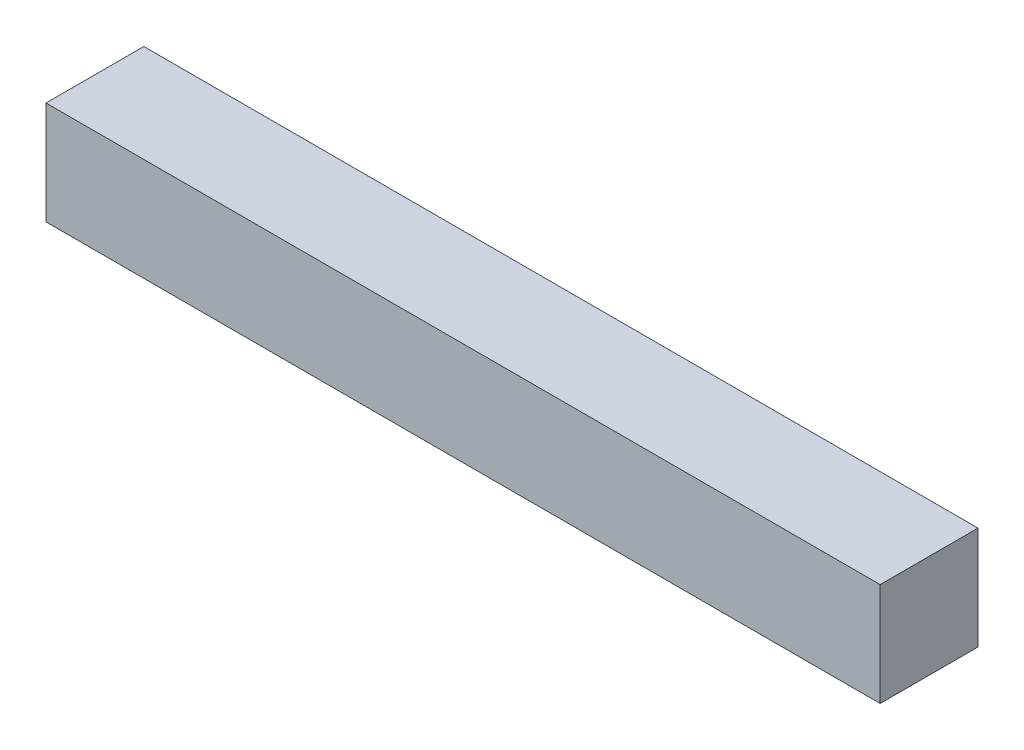
from build123d import *

# Parameters (mm, degrees)
SKETCH1_W           = 40.5
SKETCH1_H           = 5
BOSS_EXTRUDE1_DEPTH = 4.75


with BuildPart() as part:
    # Sketch1 → Boss-Extrude1 (new body)
    with BuildSketch(Plane.XY):
        with Locations((20.25, 2.5)):
            Rectangle(SKETCH1_W, SKETCH1_H)
    extrude(amount=BOSS_EXTRUDE1_DEPTH)


solid = part.part
